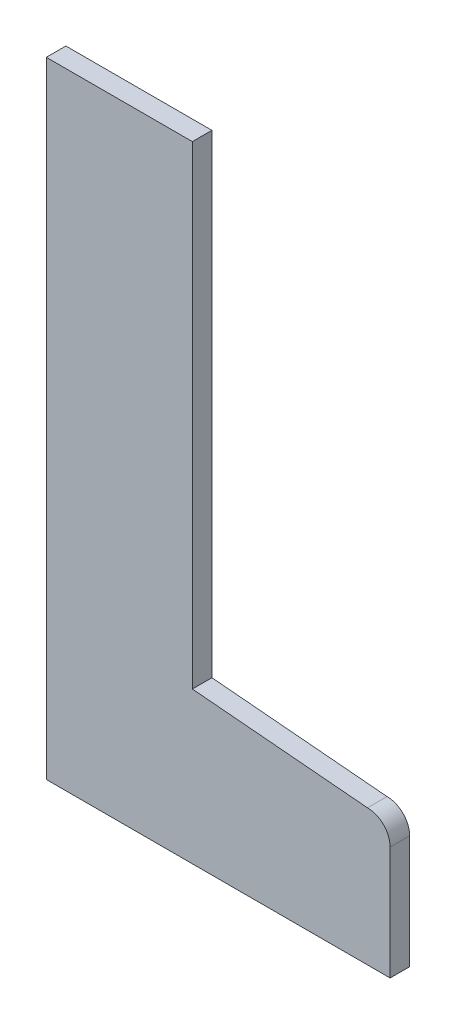
from build123d import *

# Parameters (mm, degrees)
BOSS_EXTRUDE1_DEPTH = 11.90625
SKETCH2_W           = 33.274
SKETCH2_H           = 381
CUT_EXTRUDE1_DEPTH  = 12.90625


with BuildPart() as part:
    # Sketch1 → Boss-Extrude1 (new body)
    with BuildSketch(Plane.XY):
        with BuildLine():
            Line((-101.285966724, 306.196742645), (0.115853822, 306.196742645))
            Line((0.115853822, 306.196742645), (20.943853822, 306.196742645))
            Line((20.943853822, 306.196742645), (20.943853822, 111.886742645))
            Line((20.943853822, 111.886742645), (20.943853822, 34.495334159))
            Line((20.943853822, 34.495334159), (20.943853822, 17.413022699))
            Line((20.943853822, 17.413022699), (127.616425214, 8.080381993))
            ThreePointArc((127.616425214, 8.080381993), (137.378567656, 4.036770195), (141.422179454, -5.725372247))
            Line((141.422179454, -5.725372247), (141.422179454, -74.803257355))
            Line((141.422179454, -74.803257355), (133.664033276, -74.803257355))
            Line((133.664033276, -74.803257355), (-101.285966724, -74.803257355))
            Line((-101.285966724, -74.803257355), (-101.285966724, 306.196742645))
        make_face()
    extrude(amount=BOSS_EXTRUDE1_DEPTH)

    # Sketch2 → Cut-Extrude1 (cut, through all)
    with BuildSketch(Plane.XY.offset(11.90625)):
        with Locations((-84.648966724, 115.696742645)):
            Rectangle(SKETCH2_W, SKETCH2_H)
    extrude(amount=-CUT_EXTRUDE1_DEPTH, mode=Mode.SUBTRACT)


solid = part.part
